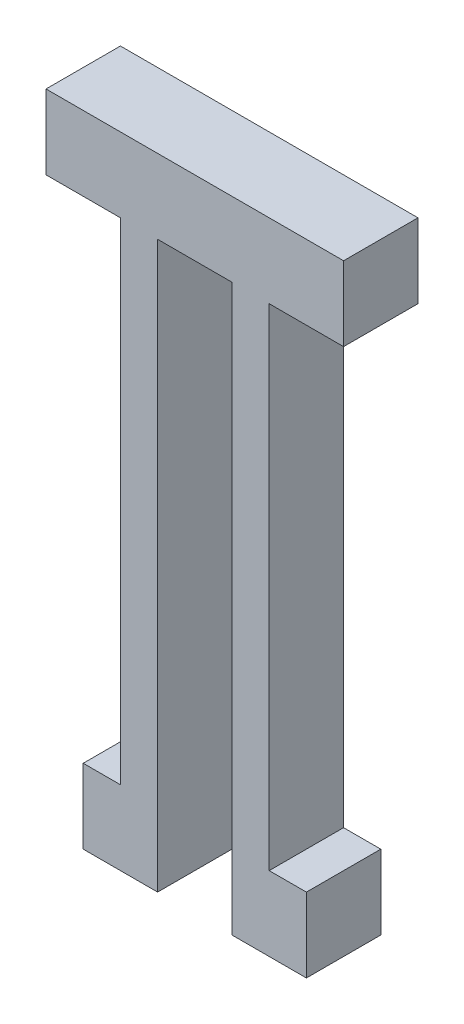
from build123d import *

# Parameters (mm, degrees)
BOSS_EXTRUDE1_DEPTH = 6.35


with BuildPart() as part:
    # Sketch1 → Boss-Extrude1 (new body)
    with BuildSketch(Plane.XY):
        Polygon((0, 0), (6.35, 0), (6.35, -41.91), (3.175, -41.91), (3.175, -48.26), (6.35, -48.26), (9.525, -48.26), (9.525, 0), (15.875, 0), (15.875, -48.26), (19.05, -48.26), (22.225, -48.26), (22.225, -41.91), (19.05, -41.91), (19.05, 0), (25.4, 0), (25.4, 6.35), (0, 6.35), align=None)
    extrude(amount=BOSS_EXTRUDE1_DEPTH)


solid = part.part
